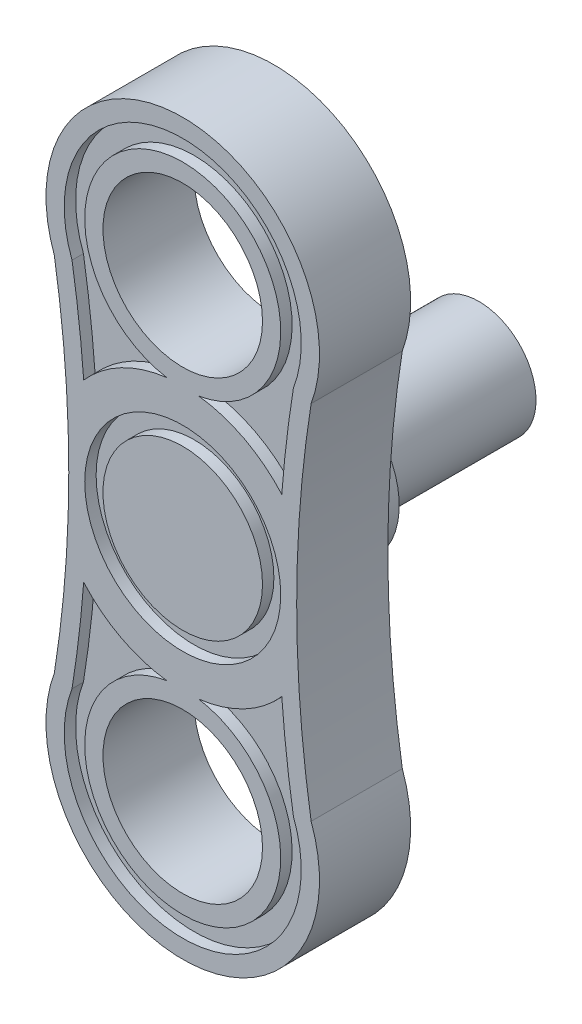
from build123d import *

# Parameters (mm, degrees)
BOSS_EXTRUDE1_DEPTH     = 40
SKETCH2_R               = 43
SKETCH2_R_2             = 35
CUT_EXTRUDE1_DEPTH      = 5
CUT_EXTRUDE2_DEPTH      = 270.814751265
CUT_EXTRUDE2_DEPTH_BACK = 270.814751265
SKETCH2_5_R             = 35
SKETCH4_R               = 35
BOSS_EXTRUDE3_DEPTH     = 20
SKETCH4_4_R             = 25
BOSS_EXTRUDE4_DEPTH     = 90


with BuildPart() as part:
    # Sketch1 → Boss-Extrude1 (new body)
    with BuildSketch(Plane.XY):
        with BuildLine():
            ThreePointArc((56.338184709, -20.639984102), (0, 60), (-56.338184709, -20.639984102))
            ThreePointArc((-56.338184709, -20.639984102), (-50, -100), (-56.338184709, -179.360015898))
            ThreePointArc((-56.338184709, -179.360015898), (0, -260), (56.338184709, -179.360015898))
            ThreePointArc((56.338184709, -179.360015898), (50, -100), (56.338184709, -20.639984102))
        make_face()
    extrude(amount=-BOSS_EXTRUDE1_DEPTH)

    # Sketch2 → Cut-Extrude1 (cut)
    # profile 1 of 3: a face of its own
    with BuildSketch(Plane.XY):
        with Locations((0, -100)):
            Circle(SKETCH2_R)
        with Locations((0, -100)):
            Circle(SKETCH2_R_2, mode=Mode.SUBTRACT)
    # profile 2 of 3: a face of its own
    with BuildSketch(Plane.XY):
        with BuildLine():
            ThreePointArc((7.008521599, -42.425), (0, 43), (-7.008521599, -42.425))
            ThreePointArc((-7.008521599, -42.425), (-26.989032945, -48.661981917), (-43.454545455, -61.585126847))
            ThreePointArc((-43.454545455, -61.585126847), (-45.552404101, -40.028148339), (-48.567238975, -18.580185639))
            ThreePointArc((-48.567238975, -18.580185639), (0, 52), (48.567238975, -18.580185639))
            ThreePointArc((48.567238975, -18.580185639), (45.552404101, -40.028148339), (43.454545455, -61.585126847))
            ThreePointArc((43.454545455, -61.585126847), (26.989032945, -48.661981917), (7.008521599, -42.425))
        make_face()
    # profile 3 of 3: a face of its own
    with BuildSketch(Plane.XY):
        with BuildLine():
            ThreePointArc((7.008521599, -157.575), (26.989032945, -151.338018083), (43.454545455, -138.414873153))
            ThreePointArc((43.454545455, -138.414873153), (45.552404101, -159.971851661), (48.567238975, -181.419814361))
            ThreePointArc((48.567238975, -181.419814361), (0, -252), (-48.567238975, -181.419814361))
            ThreePointArc((-48.567238975, -181.419814361), (-45.552404101, -159.971851661), (-43.454545455, -138.414873153))
            ThreePointArc((-43.454545455, -138.414873153), (-26.989032945, -151.338018083), (-7.008521599, -157.575))
            ThreePointArc((-7.008521599, -157.575), (0, -243), (7.008521599, -157.575))
        make_face()
    extrude(amount=-CUT_EXTRUDE1_DEPTH, mode=Mode.SUBTRACT)

    # Sketch2_5 → Cut-Extrude2 (cut, two sides: drawn at the far end of the back side and taken through both)
    with BuildSketch(Plane.XY.offset(-CUT_EXTRUDE2_DEPTH_BACK)):
        Circle(SKETCH2_5_R)
        with Locations((0, -200)):
            Circle(SKETCH2_5_R)
    extrude(amount=CUT_EXTRUDE2_DEPTH + CUT_EXTRUDE2_DEPTH_BACK, mode=Mode.SUBTRACT)

    # Sketch4 → Boss-Extrude3 (add)
    with BuildSketch(Plane(origin=(0, 0, -40), x_dir=(-1, 0, 0), z_dir=(0, 0, -1))):
        with Locations((0, -100)):
            Circle(SKETCH4_R)
    extrude(amount=BOSS_EXTRUDE3_DEPTH)

    # Sketch4_4 → Boss-Extrude4 (add)
    with BuildSketch(Plane(origin=(0, 0, -40), x_dir=(-1, 0, 0), z_dir=(0, 0, -1))):
        with Locations((0, -100)):
            Circle(SKETCH4_4_R)
    extrude(amount=BOSS_EXTRUDE4_DEPTH)


solid = part.part
